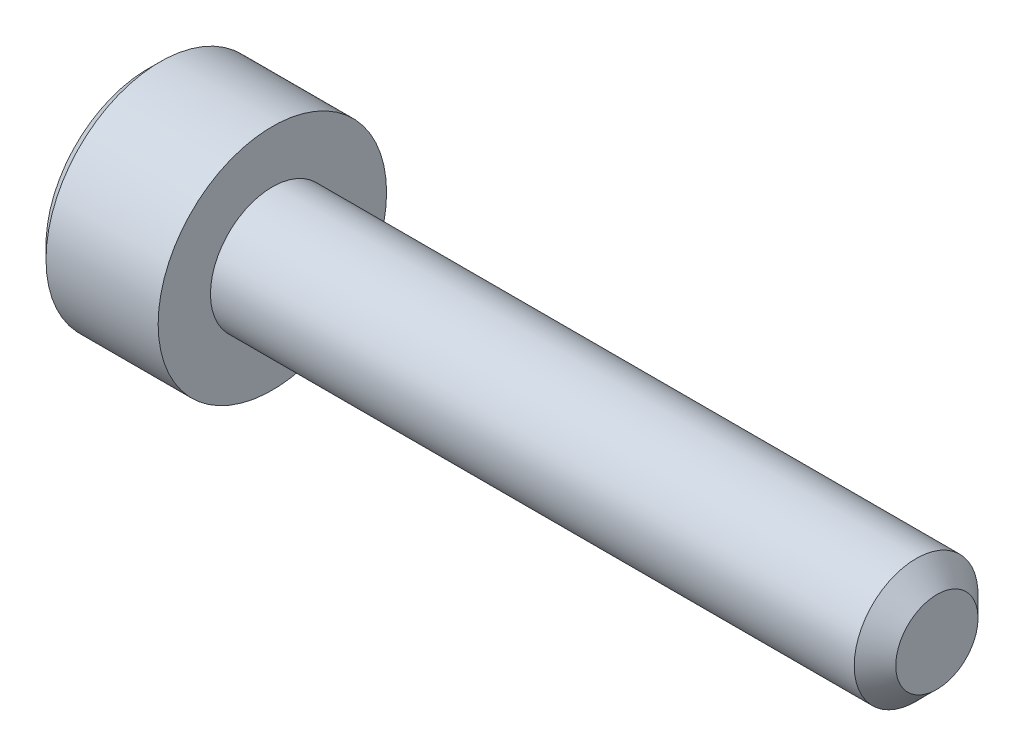
from build123d import *

# Parameters (mm, degrees)
CHAMFER1_SIZE      = 0.5
CHAMFER2_SIZE      = 0.3
CUT_EXTRUDE1_DEPTH = 2.5
CHAMFER3_SIZE      = 0.3


with BuildPart() as part:
    # Sketch1 → Revolve1 (revolve)
    with BuildSketch(Plane.XY):
        Polygon((0, 0), (0, 2.75), (3, 2.75), (3, 1.49), (19, 1.49), (19, 0), align=None)
    revolve(axis=Axis((-88.705490849, 0, 0), (1, 0, 0)))

    # Chamfer1
    chamfer1_edges = [part.edges().sort_by_distance(p)[0] for p in [
        (19, -1.49, 0),
    ]]
    chamfer(chamfer1_edges, length=CHAMFER1_SIZE)

    # Chamfer2
    chamfer2_edges = [part.edges().sort_by_distance(p)[0] for p in [
        (0, -2.75, 0),
    ]]
    chamfer(chamfer2_edges, length=CHAMFER2_SIZE)

    # Sketch3 → Cut-Extrude1 (cut)
    with BuildSketch(Plane(origin=(0, 0, 0), x_dir=(0, 0, -1), z_dir=(1, 0, 0))):
        Polygon((-1.443375673, 0), (-0.721687836, -1.25), (0.721687836, -1.25), (1.443375673, 0), (0.721687836, 1.25), (-0.721687836, 1.25), align=None)
    extrude(amount=CUT_EXTRUDE1_DEPTH, mode=Mode.SUBTRACT)

    # Chamfer3
    chamfer3_edges = [part.edges().sort_by_distance(p)[0] for p in [
        (0, 1.25, 0),
        (0, 0.625, 1.082531755),
        (0, -0.625, 1.082531755),
        (0, -1.25, 0),
        (0, -0.625, -1.082531755),
        (0, 0.625, -1.082531755),
    ]]
    chamfer(chamfer3_edges, length=CHAMFER3_SIZE)


solid = part.part
